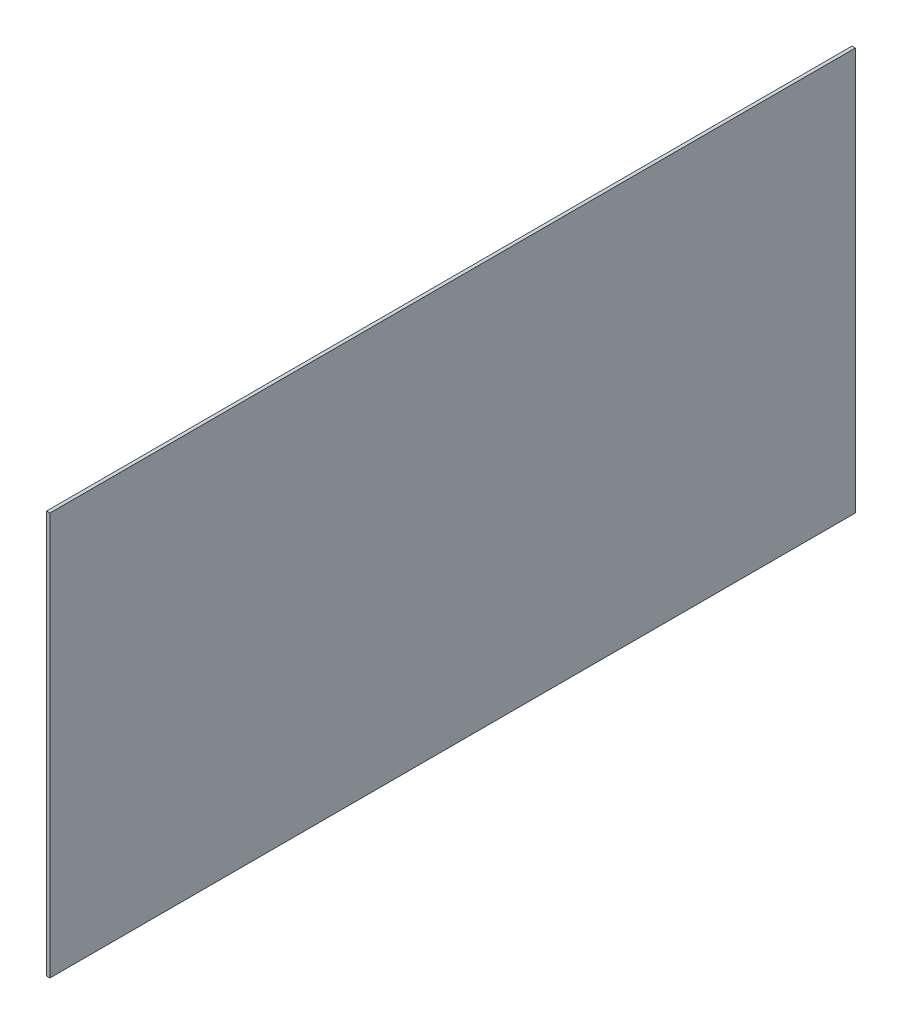
from build123d import *

# Parameters (mm, degrees)
SKETCH1_W           = 609.6
SKETCH1_H           = 304.8
BOSS_EXTRUDE1_DEPTH = 2.54


with BuildPart() as part:
    # Sketch1 → Boss-Extrude1 (new body)
    with BuildSketch(Plane(origin=(0, 0, 0), x_dir=(0, 0, -1), z_dir=(1, 0, 0))):
        Rectangle(SKETCH1_W, SKETCH1_H)
    extrude(amount=BOSS_EXTRUDE1_DEPTH)


solid = part.part
